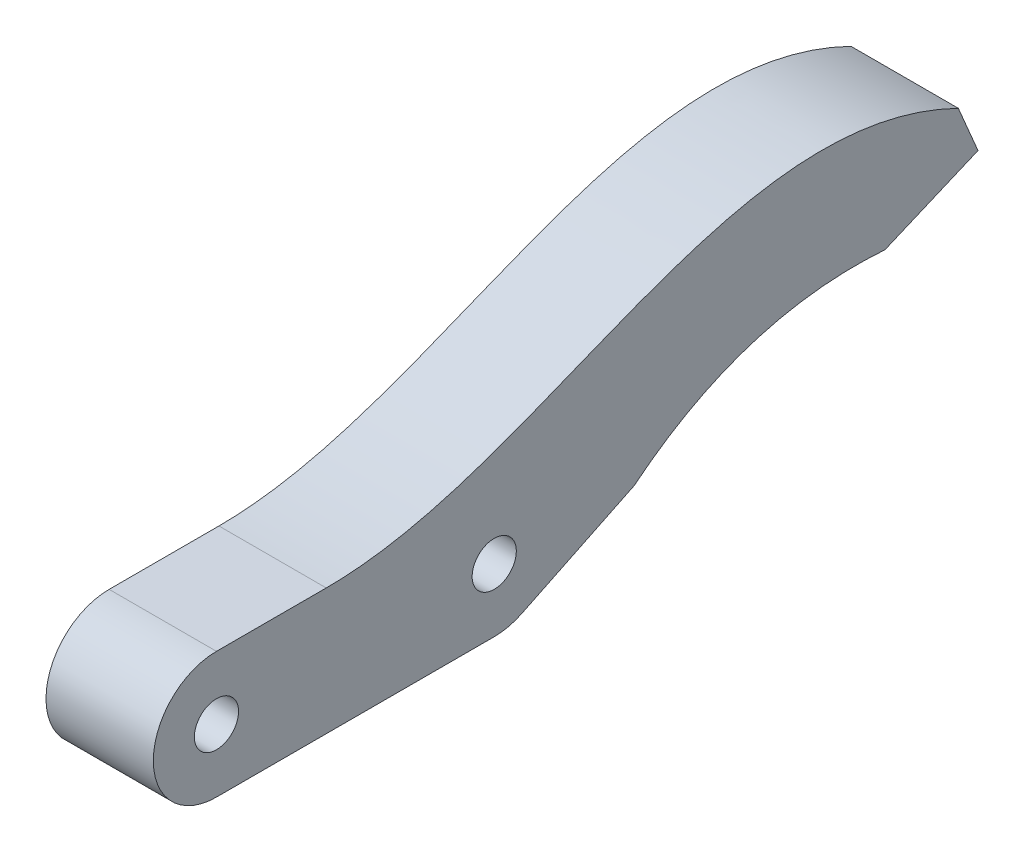
from build123d import *

# Parameters (mm, degrees)
SKETCH1_R           = 1.75
BOSS_EXTRUDE1_DEPTH = 8.5
BOSS_EXTRUDE2_DEPTH = 8.5


with BuildPart() as part:
    # Sketch1 → Boss-Extrude1 (new body)
    with BuildSketch(Plane(origin=(0, 0, 0), x_dir=(0, 0, -1), z_dir=(1, 0, 0))):
        with BuildLine():
            Line((27, 10), (5, 10))
            ThreePointArc((5, 10), (0, 5), (5, 0))
            Line((5, 0), (27, 0))
            ThreePointArc((27, 0), (32, 5), (27, 10))
        make_face()
        with Locations((5, 5)):
            Circle(SKETCH1_R, mode=Mode.SUBTRACT)
        with Locations((27, 5)):
            Circle(SKETCH1_R, mode=Mode.SUBTRACT)
    extrude(amount=BOSS_EXTRUDE1_DEPTH)

    # Sketch2 → Boss-Extrude2 (add)
    with BuildSketch(Plane(origin=(8.5, 0, 0), x_dir=(0, 0, -1), z_dir=(1, 0, 0))):
        with BuildLine():
            add(Edge.make_bspline(
                [(63.752972286, 17.872423117), (45.928882678, 26.563787963), (31.059268621, 10), (13.694974759, 10)],
                knots=[0, 0, 0, 0, 1, 1, 1, 1], degree=3))
            Line((13.694974759, 10), (27, 10))
            ThreePointArc((27, 10), (31.87285141, 6.120410255), (29.183837075, 0.502127655))
            Line((29.183837075, 0.502127655), (38.08542066, 4.824084077))
            add(Edge.make_bspline(
                [(38.08542066, 4.824084077), (46.797509509, 11.895222457), (57.948000409, 11.067843667)],
                knots=[0, 0, 0, 1, 1, 1], degree=2))
            Line((57.948000409, 11.067843667), (65.313809691, 14.189518476))
            Line((65.313809691, 14.189518476), (63.752972286, 17.872423117))
        make_face()
    extrude(amount=-BOSS_EXTRUDE2_DEPTH)


solid = part.part
